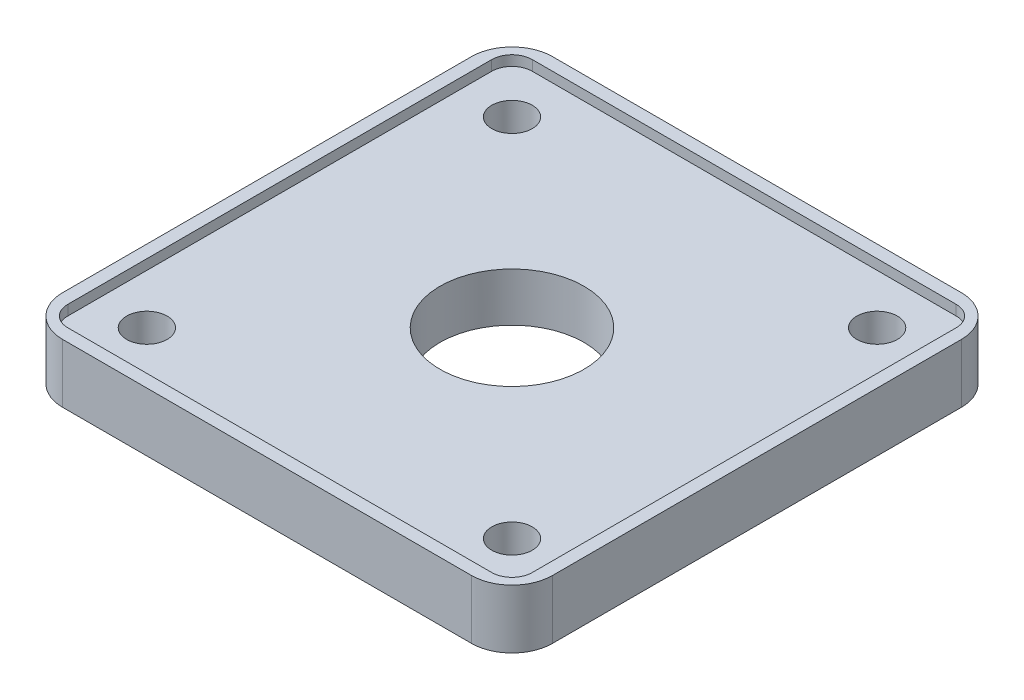
from build123d import *

# Parameters (mm, degrees)
IZIM1_R                     = 7.1
IZIM1_R_2                   = 2
Y_KSEKLIK_EKSTR_ZYON1_DEPTH = 5.8
KES_EKSTR_ZYON1_DEPTH       = 1


with BuildPart() as part:
    # Çizim1 → Yükseklik-Ekstrüzyon1 (new body)
    with BuildSketch(Plane(origin=(0, 0, 0), x_dir=(1, 0, 0), z_dir=(0, 1, 0))):
        with BuildLine():
            Line((-20.15, -24.15), (20.15, -24.15))
            ThreePointArc((20.15, -24.15), (22.978427125, -22.978427125), (24.15, -20.15))
            Line((24.15, -20.15), (24.15, 20.15))
            ThreePointArc((24.15, 20.15), (22.978427125, 22.978427125), (20.15, 24.15))
            Line((20.15, 24.15), (-20.15, 24.15))
            ThreePointArc((-20.15, 24.15), (-22.978427125, 22.978427125), (-24.15, 20.15))
            Line((-24.15, 20.15), (-24.15, -20.15))
            ThreePointArc((-24.15, -20.15), (-22.978427125, -22.978427125), (-20.15, -24.15))
        make_face()
        Circle(IZIM1_R, mode=Mode.SUBTRACT)
        with Locations((-18, 18)):
            Circle(IZIM1_R_2, mode=Mode.SUBTRACT)
        with Locations((-18, -18)):
            Circle(IZIM1_R_2, mode=Mode.SUBTRACT)
        with Locations((18, -18)):
            Circle(IZIM1_R_2, mode=Mode.SUBTRACT)
        with Locations((18, 18)):
            Circle(IZIM1_R_2, mode=Mode.SUBTRACT)
    extrude(amount=Y_KSEKLIK_EKSTR_ZYON1_DEPTH)

    # Çizim2 → Kes-Ekstrüzyon1 (cut)
    with BuildSketch(Plane(origin=(0, 5.8, 0), x_dir=(1, 0, 0), z_dir=(0, 1, 0))):
        with BuildLine():
            Line((-20.9, -22.9), (20.9, -22.9))
            ThreePointArc((20.9, -22.9), (22.314213562, -22.314213562), (22.9, -20.9))
            Line((22.9, -20.9), (22.9, 20.9))
            ThreePointArc((22.9, 20.9), (22.314213562, 22.314213562), (20.9, 22.9))
            Line((20.9, 22.9), (-20.9, 22.9))
            ThreePointArc((-20.9, 22.9), (-22.314213562, 22.314213562), (-22.9, 20.9))
            Line((-22.9, 20.9), (-22.9, -20.9))
            ThreePointArc((-22.9, -20.9), (-22.314213562, -22.314213562), (-20.9, -22.9))
        make_face()
    extrude(amount=-KES_EKSTR_ZYON1_DEPTH, mode=Mode.SUBTRACT)


solid = part.part
